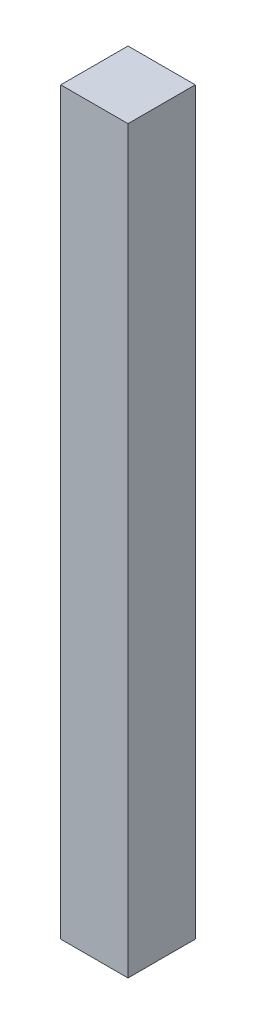
from build123d import *

# Parameters (mm, degrees)
SKETCH1_W           = 25.4
SKETCH1_H           = 25.4
BOSS_EXTRUDE1_DEPTH = 279.4


with BuildPart() as part:
    # Sketch1 → Boss-Extrude1 (new body)
    with BuildSketch(Plane(origin=(0, 0, 0), x_dir=(1, 0, 0), z_dir=(0, 1, 0))):
        with Locations((12.7, 12.7)):
            Rectangle(SKETCH1_W, SKETCH1_H)
    extrude(amount=BOSS_EXTRUDE1_DEPTH)


solid = part.part
